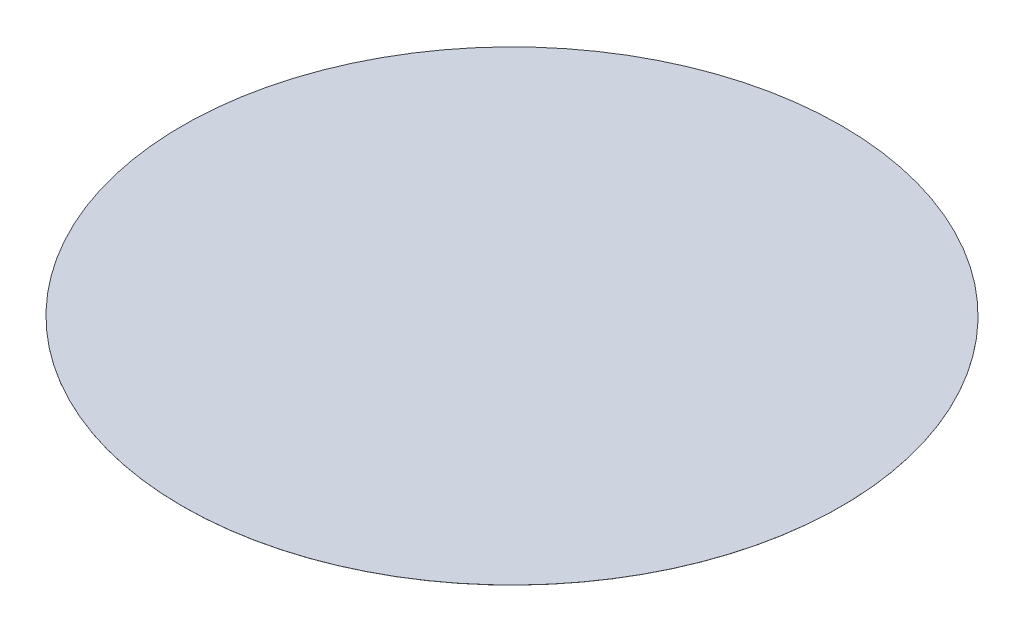
from build123d import *

# Parameters (mm, degrees)
BOSS_EXTRUDE1_DEPTH = 0.25
CIRPATTERN11_COUNT  = 6


with BuildPart() as part:
    # Sketch1 → Boss-Extrude1 (new body)
    with BuildSketch(Plane(origin=(0, 0, 0), x_dir=(1, 0, 0), z_dir=(0, 1, 0))):
        with BuildLine():
            Line((0, 0), (973.479438029, 612.239972343))
            ThreePointArc((973.479438029, 612.239972343), (1104.988994002, 318.589584157), (1150, 0))
            ThreePointArc((1150, 0), (1116.243331787, -276.58782374), (1016.955088276, -536.937937223))
            Line((1016.955088276, -536.937937223), (0, 0))
        make_face()
    boss_extrude1 = extrude(amount=BOSS_EXTRUDE1_DEPTH)

    # CirPattern11: Boss-Extrude1 ×6 about axis
    cirpattern11_axis = Axis((0, 28.800854228, 0), (0, -1, 0))
    for i in range(1, CIRPATTERN11_COUNT):
        add(boss_extrude1.rotate(cirpattern11_axis, i * 360 / CIRPATTERN11_COUNT))


solid = part.part
